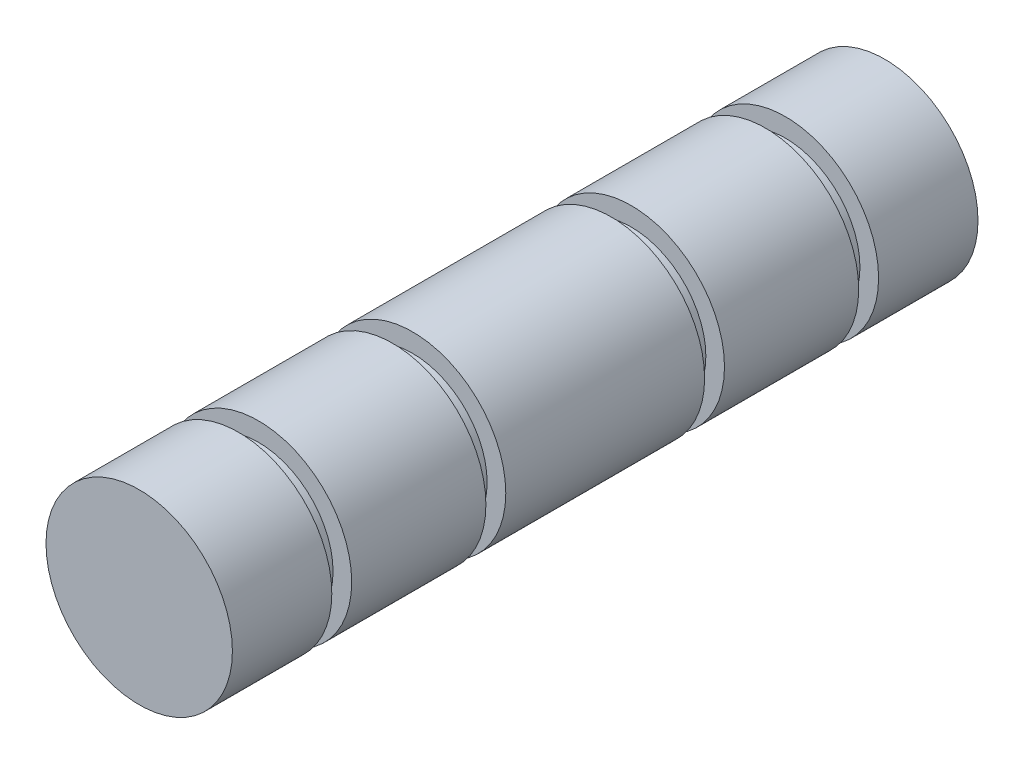
from build123d import *

# Parameters (mm, degrees)
SKETCH1_R           = 4.7625
BOSS_EXTRUDE1_DEPTH = 19.05
SKETCH2_W           = 0.9525
SKETCH2_H           = 1.016


with BuildPart() as part:
    # Sketch1 → Boss-Extrude1 (new body, symmetric)
    with BuildSketch(Plane.XY):
        Circle(SKETCH1_R)
    extrude(amount=BOSS_EXTRUDE1_DEPTH, both=True)

    # Sketch2 → Cut-Revolve1 (revolve, cut)
    with BuildSketch(Plane(origin=(0, 0, 0), x_dir=(1, 0, 0), z_dir=(0, 1, 0))):
        with Locations((4.28625, 13.462)):
            Rectangle(SKETCH2_W, SKETCH2_H)
        with Locations((4.28625, -13.462)):
            Rectangle(SKETCH2_W, SKETCH2_H)
        with Locations((4.28625, 5.588)):
            Rectangle(SKETCH2_W, SKETCH2_H)
        with Locations((4.28625, -5.588)):
            Rectangle(SKETCH2_W, SKETCH2_H)
    revolve(axis=Axis((0, 0, 19.05), (0, 0, -1)), mode=Mode.SUBTRACT)


solid = part.part
